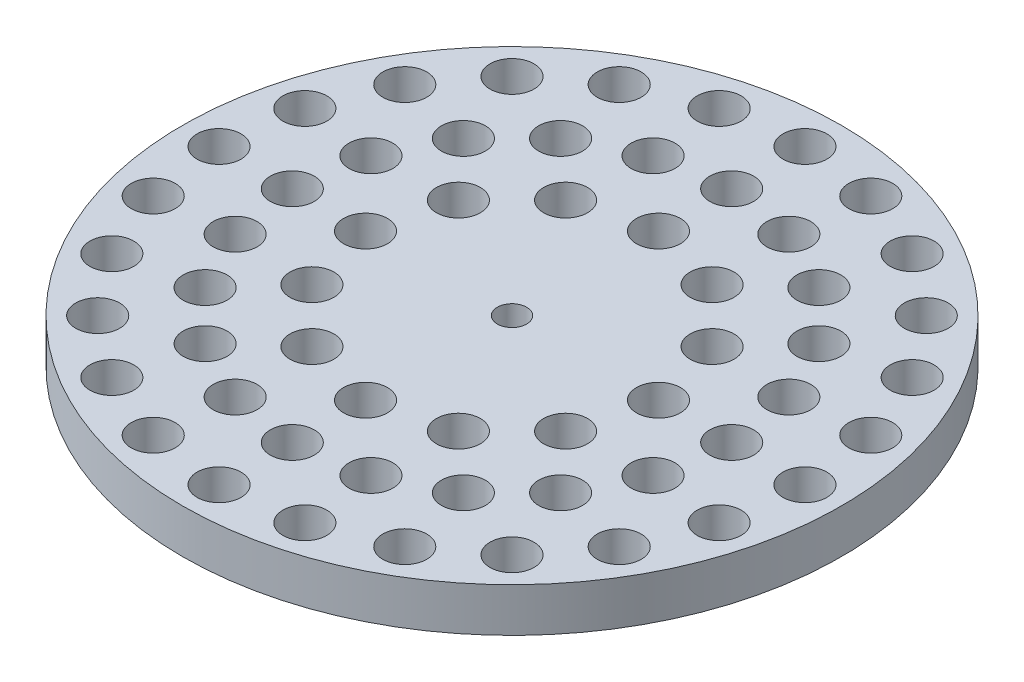
from build123d import *

# Parameters (mm, degrees)
ESBO_O1_R                = 5
ESBO_O1_R_2              = 3.5
RESSALTO_EXTRUS_O1_DEPTH = 3.6
ESBO_O4_R                = 22.5
RESSALTO_EXTRUS_O2_DEPTH = 3
ESBO_O5_R                = 1
ESBO_O5_R_2              = 1.5
CORTE_EXTRUS_O2_DEPTH    = 7.6


with BuildPart() as part:
    # Esboço1 → Ressalto-extrusão1 (new body)
    with BuildSketch(Plane(origin=(0, 0, 0), x_dir=(1, 0, 0), z_dir=(0, 1, 0))):
        Circle(ESBO_O1_R)
        Circle(ESBO_O1_R_2, mode=Mode.SUBTRACT)
    extrude(amount=RESSALTO_EXTRUS_O1_DEPTH)

    # Esboço4 → Ressalto-extrusão2 (add)
    with BuildSketch(Plane(origin=(0, 3.6, 0), x_dir=(1, 0, 0), z_dir=(0, 1, 0))):
        Circle(ESBO_O4_R)
    extrude(amount=RESSALTO_EXTRUS_O2_DEPTH)

    # Esboço5 → Corte-extrusão2 (cut, through all)
    with BuildSketch(Plane(origin=(0, 6.6, 0), x_dir=(1, 0, 0), z_dir=(0, 1, 0))):
        Circle(ESBO_O5_R)
        with Locations((0, 20)):
            Circle(ESBO_O5_R_2)
        with Locations((0, 15)):
            Circle(ESBO_O5_R_2)
        with Locations((0, 10)):
            Circle(ESBO_O5_R_2)
        with Locations((5, 8.660254038)):
            Circle(ESBO_O5_R_2)
        with Locations((8.660254038, 5)):
            Circle(ESBO_O5_R_2)
        with Locations((10, 0)):
            Circle(ESBO_O5_R_2)
        with Locations((8.660254038, -5)):
            Circle(ESBO_O5_R_2)
        with Locations((5, -8.660254038)):
            Circle(ESBO_O5_R_2)
        with Locations((0, -10)):
            Circle(ESBO_O5_R_2)
        with Locations((-5, -8.660254038)):
            Circle(ESBO_O5_R_2)
        with Locations((-8.660254038, -5)):
            Circle(ESBO_O5_R_2)
        with Locations((-10, 0)):
            Circle(ESBO_O5_R_2)
        with Locations((-8.660254038, 5)):
            Circle(ESBO_O5_R_2)
        with Locations((-5, 8.660254038)):
            Circle(ESBO_O5_R_2)
        with Locations((4.635254916, 14.265847744)):
            Circle(ESBO_O5_R_2)
        with Locations((8.816778784, 12.135254916)):
            Circle(ESBO_O5_R_2)
        with Locations((12.135254916, 8.816778784)):
            Circle(ESBO_O5_R_2)
        with Locations((14.265847744, 4.635254916)):
            Circle(ESBO_O5_R_2)
        with Locations((15, 0)):
            Circle(ESBO_O5_R_2)
        with Locations((14.265847744, -4.635254916)):
            Circle(ESBO_O5_R_2)
        with Locations((12.135254916, -8.816778784)):
            Circle(ESBO_O5_R_2)
        with Locations((8.816778784, -12.135254916)):
            Circle(ESBO_O5_R_2)
        with Locations((4.635254916, -14.265847744)):
            Circle(ESBO_O5_R_2)
        with Locations((0, -15)):
            Circle(ESBO_O5_R_2)
        with Locations((-4.635254916, -14.265847744)):
            Circle(ESBO_O5_R_2)
        with Locations((-8.816778784, -12.135254916)):
            Circle(ESBO_O5_R_2)
        with Locations((-12.135254916, -8.816778784)):
            Circle(ESBO_O5_R_2)
        with Locations((-14.265847744, -4.635254916)):
            Circle(ESBO_O5_R_2)
        with Locations((-15, 0)):
            Circle(ESBO_O5_R_2)
        with Locations((-14.265847744, 4.635254916)):
            Circle(ESBO_O5_R_2)
        with Locations((-12.135254916, 8.816778784)):
            Circle(ESBO_O5_R_2)
        with Locations((-8.816778784, 12.135254916)):
            Circle(ESBO_O5_R_2)
        with Locations((-4.635254916, 14.265847744)):
            Circle(ESBO_O5_R_2)
        with Locations((5.176380902, 19.318516526)):
            Circle(ESBO_O5_R_2)
        with Locations((10, 17.320508076)):
            Circle(ESBO_O5_R_2)
        with Locations((14.142135624, 14.142135624)):
            Circle(ESBO_O5_R_2)
        with Locations((17.320508076, 10)):
            Circle(ESBO_O5_R_2)
        with Locations((19.318516526, 5.176380902)):
            Circle(ESBO_O5_R_2)
        with Locations((20, 0)):
            Circle(ESBO_O5_R_2)
        with Locations((19.318516526, -5.176380902)):
            Circle(ESBO_O5_R_2)
        with Locations((17.320508076, -10)):
            Circle(ESBO_O5_R_2)
        with Locations((14.142135624, -14.142135624)):
            Circle(ESBO_O5_R_2)
        with Locations((10, -17.320508076)):
            Circle(ESBO_O5_R_2)
        with Locations((5.176380902, -19.318516526)):
            Circle(ESBO_O5_R_2)
        with Locations((0, -20)):
            Circle(ESBO_O5_R_2)
        with Locations((-5.176380902, -19.318516526)):
            Circle(ESBO_O5_R_2)
        with Locations((-10, -17.320508076)):
            Circle(ESBO_O5_R_2)
        with Locations((-14.142135624, -14.142135624)):
            Circle(ESBO_O5_R_2)
        with Locations((-17.320508076, -10)):
            Circle(ESBO_O5_R_2)
        with Locations((-19.318516526, -5.176380902)):
            Circle(ESBO_O5_R_2)
        with Locations((-20, 0)):
            Circle(ESBO_O5_R_2)
        with Locations((-19.318516526, 5.176380902)):
            Circle(ESBO_O5_R_2)
        with Locations((-17.320508076, 10)):
            Circle(ESBO_O5_R_2)
        with Locations((-14.142135624, 14.142135624)):
            Circle(ESBO_O5_R_2)
        with Locations((-10, 17.320508076)):
            Circle(ESBO_O5_R_2)
        with Locations((-5.176380902, 19.318516526)):
            Circle(ESBO_O5_R_2)
    extrude(amount=-CORTE_EXTRUS_O2_DEPTH, mode=Mode.SUBTRACT)


solid = part.part
